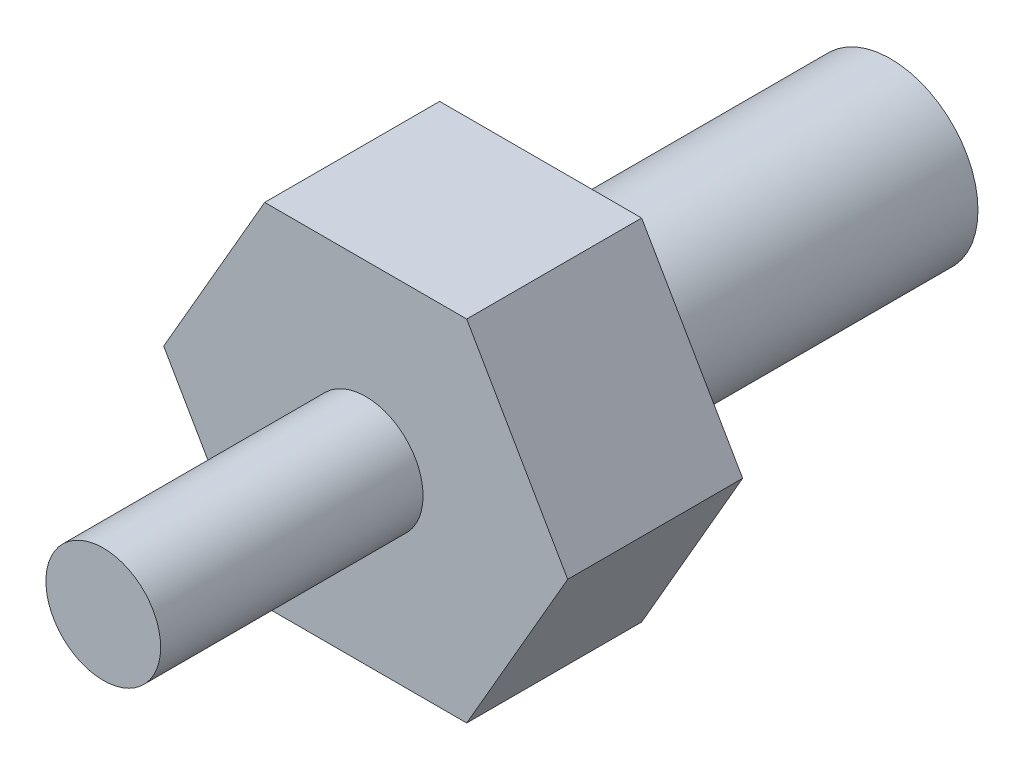
from build123d import *

# Parameters (mm, degrees)
SKETCH1_R           = 3.175
BOSS_EXTRUDE1_DEPTH = 12.7
BOSS_EXTRUDE2_DEPTH = 6.35
SKETCH3_R           = 2.0828
BOSS_EXTRUDE3_DEPTH = 9.525


with BuildPart() as part:
    # Sketch1 → Boss-Extrude1 (new body)
    with BuildSketch(Plane.XY):
        Circle(SKETCH1_R)
    extrude(amount=BOSS_EXTRUDE1_DEPTH)

    # Sketch2 → Boss-Extrude2 (add)
    with BuildSketch(Plane.XY.offset(12.7)):
        Polygon((3.666174209, -6.35), (7.332348419, 0), (3.666174209, 6.35), (-3.666174209, 6.35), (-7.332348419, 0), (-3.666174209, -6.35), align=None)
    extrude(amount=BOSS_EXTRUDE2_DEPTH)

    # Sketch3 → Boss-Extrude3 (add)
    with BuildSketch(Plane.XY.offset(19.05)):
        Circle(SKETCH3_R)
    extrude(amount=BOSS_EXTRUDE3_DEPTH)


solid = part.part
